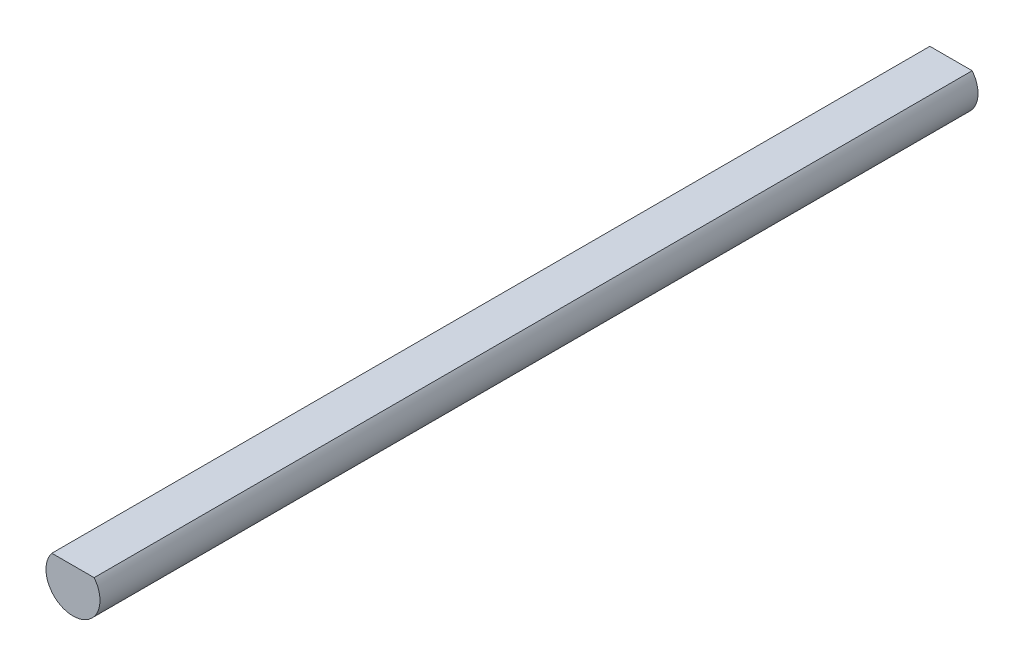
from build123d import *

# Parameters (mm, degrees)
SKETCH2_R               = 4
BOSS_EXTRUDE1_DEPTH     = 130
CUT_EXTRUDE1_DEPTH      = 1
CUT_EXTRUDE1_DEPTH_BACK = 131


with BuildPart() as part:
    # Sketch2 → Boss-Extrude1 (new body)
    with BuildSketch(Plane.XY):
        Circle(SKETCH2_R)
    extrude(amount=BOSS_EXTRUDE1_DEPTH)

    # Sketch3 → Cut-Extrude1 (cut, two sides)
    with BuildSketch(Plane.XY.offset(130)) as cut_extrude1_sk:
        with BuildLine():
            Line((-3.130999283, 2.489345996), (3.130999283, 2.489345996))
            ThreePointArc((3.130999283, 2.489345996), (0, 4), (-3.130999283, 2.489345996))
        make_face()
    extrude(amount=CUT_EXTRUDE1_DEPTH, mode=Mode.SUBTRACT)
    extrude(cut_extrude1_sk.sketch, amount=-CUT_EXTRUDE1_DEPTH_BACK, mode=Mode.SUBTRACT)


solid = part.part
